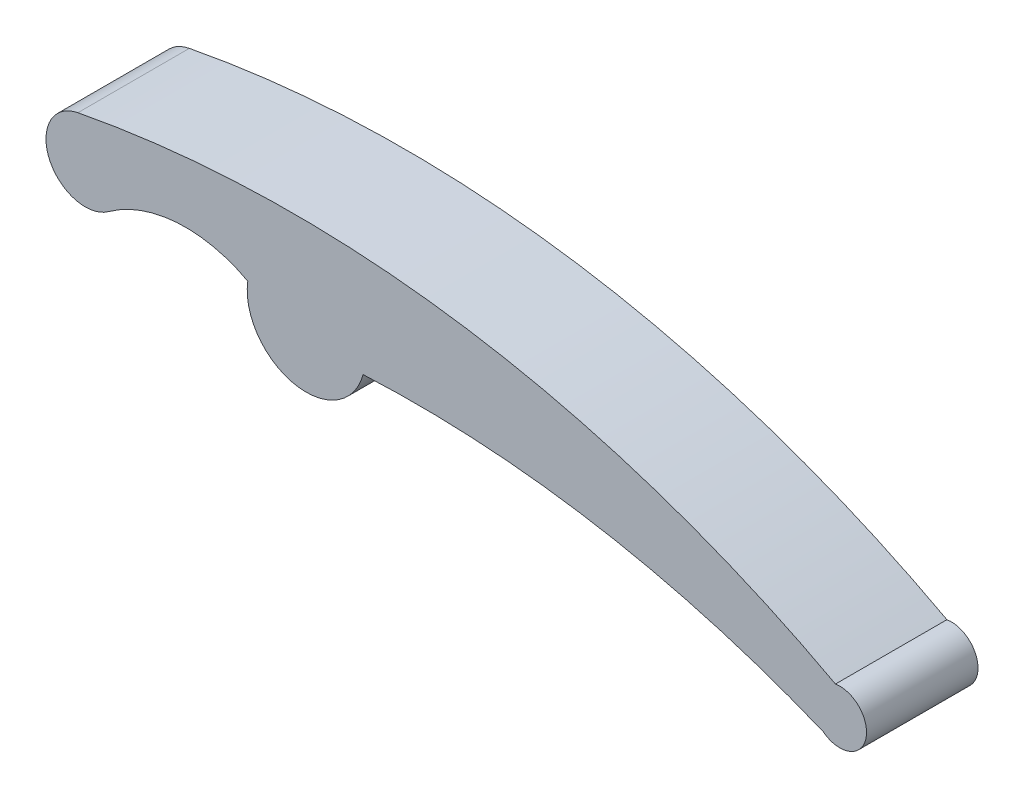
from build123d import *

# Parameters (mm, degrees)
EXTRUDE_1_DEPTH = 30


with BuildPart() as part:
    # 草图1 → 凸台-拉伸1 (new body)
    with BuildSketch(Plane.XY):
        with BuildLine():
            ThreePointArc((-15.712331266, 2.160724411), (-3.13309904, -15.547661374), (15.322874863, -4.093359222))
            ThreePointArc((15.322874863, -4.093359222), (78.436182954, -7.922682958), (139.19729869, -25.416687445))
            ThreePointArc((139.19729869, -25.416687445), (150.619110519, -21.552265679), (142.48119841, -12.654742004))
            ThreePointArc((142.48119841, -12.654742004), (43.215780263, 20.546958672), (-61.436350738, 18.570182304))
            ThreePointArc((-61.436350738, 18.570182304), (-69.151102392, 3.965497782), (-53.217470305, -0.385774624))
            ThreePointArc((-53.217470305, -0.385774624), (-34.831522248, 6.287119165), (-15.712331266, 2.160724411))
        make_face()
    extrude(amount=EXTRUDE_1_DEPTH)


solid = part.part
